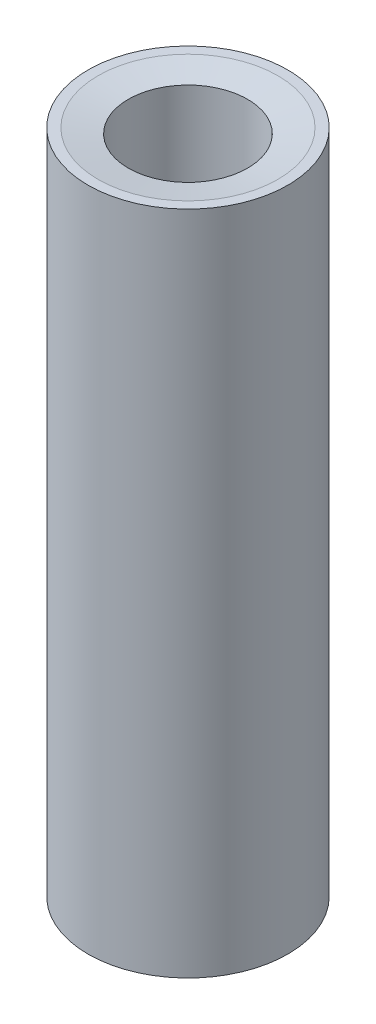
from build123d import *

# Parameters (mm, degrees)
SKETCH1_R                                 = 2.38125
EXTRUDE1_DEPTH                            = 15.875
F_4_40_TAPPED_HOLE1_D                     = 2.2606
F_4_40_TAPPED_HOLE1_DEPTH                 = 7.62
F_4_40_TAPPED_HOLE1_CBORE_D               = 2.8448
F_4_40_TAPPED_HOLE1_CBORE_DEPTH           = 5.588
F_4_40_TAPPED_HOLE1_TIP                   = 0.679152758
F_4_40_TAPPED_HOLE1_ON_FACE_2_D           = 2.2606
F_4_40_TAPPED_HOLE1_ON_FACE_2_DEPTH       = 7.62
F_4_40_TAPPED_HOLE1_ON_FACE_2_CBORE_D     = 2.8448
F_4_40_TAPPED_HOLE1_ON_FACE_2_CBORE_DEPTH = 5.588
F_4_40_TAPPED_HOLE1_ON_FACE_2_TIP         = 0.679152758
CHAMFER1_SIZE                             = 0.127
CHAMFER1_SIZE2                            = 0.720252791


with BuildPart() as part:
    # Sketch1 → Extrude1 (new body)
    with BuildSketch(Plane(origin=(0, 0, 0), x_dir=(1, 0, 0), z_dir=(0, 1, 0))):
        with Locations(Location((0, 0, 0), (0, 0, 270))):  # turned: the seam where the file's is
            Circle(SKETCH1_R)
    extrude(amount=EXTRUDE1_DEPTH)

    # #4-40 Tapped Hole1
    with Locations(Plane.ZX.offset(15.875)):
        with Locations((0, 0)):
            CounterBoreHole(F_4_40_TAPPED_HOLE1_D / 2, F_4_40_TAPPED_HOLE1_CBORE_D / 2, F_4_40_TAPPED_HOLE1_CBORE_DEPTH, depth=F_4_40_TAPPED_HOLE1_DEPTH)
            with Locations((0, 0, -(F_4_40_TAPPED_HOLE1_DEPTH + F_4_40_TAPPED_HOLE1_TIP / 2))):  # 118° drill point
                Cone(0, F_4_40_TAPPED_HOLE1_D / 2, F_4_40_TAPPED_HOLE1_TIP, mode=Mode.SUBTRACT)

    # #4-40 Tapped Hole1 on face 2
    with Locations(Plane(origin=(0, 0, 0), x_dir=(0, 0, -1), z_dir=(0, -1, 0))):
        with Locations((0, 0)):
            CounterBoreHole(F_4_40_TAPPED_HOLE1_ON_FACE_2_D / 2, F_4_40_TAPPED_HOLE1_ON_FACE_2_CBORE_D / 2, F_4_40_TAPPED_HOLE1_ON_FACE_2_CBORE_DEPTH, depth=F_4_40_TAPPED_HOLE1_ON_FACE_2_DEPTH)
            with Locations((0, 0, -(F_4_40_TAPPED_HOLE1_ON_FACE_2_DEPTH + F_4_40_TAPPED_HOLE1_ON_FACE_2_TIP / 2))):  # 118° drill point
                Cone(0, F_4_40_TAPPED_HOLE1_ON_FACE_2_D / 2, F_4_40_TAPPED_HOLE1_ON_FACE_2_TIP, mode=Mode.SUBTRACT)

    # Chamfer1
    chamfer1_edges = [part.edges().sort_by_distance(p)[0] for p in [
        (0, 15.875, -1.4224),
    ]]
    chamfer1_side = [part.faces().sort_by_distance(p)[0] for p in [
        (0, 13.081, -1.4224),
    ]]
    chamfer(chamfer1_edges, length=CHAMFER1_SIZE, length2=CHAMFER1_SIZE2, reference=chamfer1_side[0])


solid = part.part
